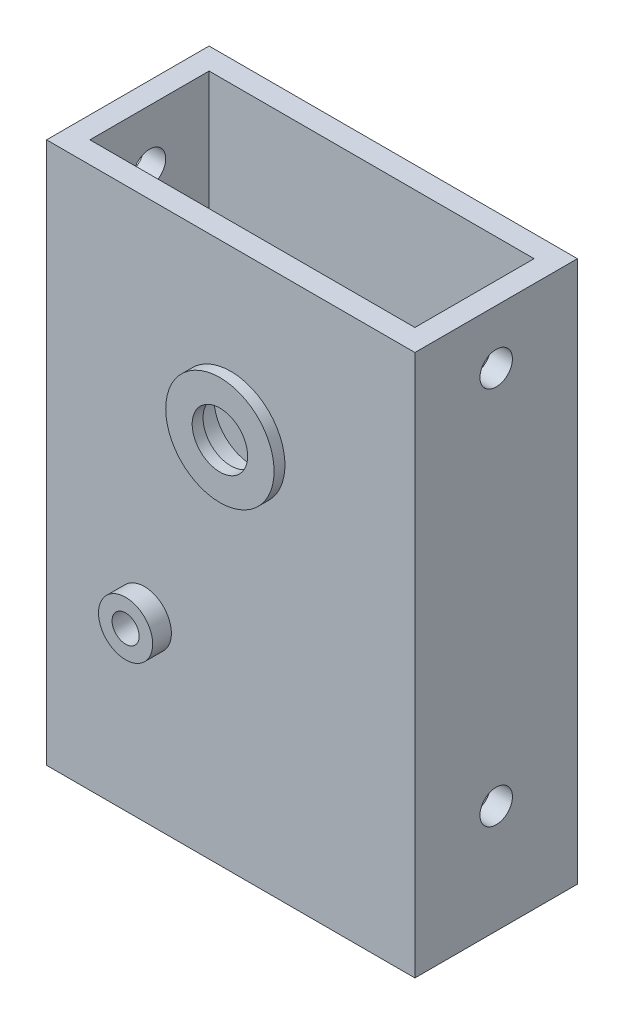
from build123d import *

# Parameters (mm, degrees)
SKETCH1_W               = 86.36
SKETCH1_H               = 38.1
SKETCH1_W_2             = 76.2
SKETCH1_H_2             = 27.94
BOSS_EXTRUDE1_DEPTH     = 127
SKETCH2_R               = 9.000000018
SKETCH2_R_2             = 3.175
CUT_EXTRUDE1_DEPTH      = 156.521858271
SKETCH3_R               = 3.81
CUT_EXTRUDE2_DEPTH      = 158.090324336
CUT_EXTRUDE2_DEPTH_BACK = 158.090324336
SKETCH4_R               = 6.35
SKETCH4_R_2             = 3.175
BOSS_EXTRUDE2_DEPTH     = 4.385
SKETCH5_R               = 6.35
SKETCH5_R_2             = 3.175
BOSS_EXTRUDE3_DEPTH     = 4.38500012
SKETCH6_R               = 12.7
SKETCH6_R_2             = 6.5
BOSS_EXTRUDE4_DEPTH     = 2.54
SKETCH7_R               = 12.7
SKETCH7_R_2             = 6.5
BOSS_EXTRUDE5_DEPTH     = 2.54


with BuildPart() as part:
    # Sketch1 → Boss-Extrude1 (new body)
    with BuildSketch(Plane(origin=(0, 0, 0), x_dir=(1, 0, 0), z_dir=(0, 1, 0))):
        with Locations((38.1, 13.97)):
            Rectangle(SKETCH1_W, SKETCH1_H)
        with Locations((38.1, 13.97)):
            Rectangle(SKETCH1_W_2, SKETCH1_H_2, mode=Mode.SUBTRACT)
    extrude(amount=BOSS_EXTRUDE1_DEPTH)

    # Sketch2 → Cut-Extrude1 (cut, through all)
    with BuildSketch(Plane.XY.offset(5.08)):
        with Locations((38.1, 88.9)):
            Circle(SKETCH2_R)
        with Locations((17.833355107, 41.428109825)):
            Circle(SKETCH2_R_2)
    extrude(amount=-CUT_EXTRUDE1_DEPTH, mode=Mode.SUBTRACT)

    # Sketch3 → Cut-Extrude2 (cut, two sides)
    with BuildSketch(Plane(origin=(81.28, 0, 0), x_dir=(0, 0, -1), z_dir=(1, 0, 0))) as cut_extrude2_sk:
        with Locations(Location((13.97, 114.3, 0), (0, 0, 180))):
            Circle(SKETCH3_R)
        with Locations(Location((13.97, 25.4, 0), (0, 0, 180))):
            Circle(SKETCH3_R)
    extrude(amount=CUT_EXTRUDE2_DEPTH, mode=Mode.SUBTRACT)
    extrude(cut_extrude2_sk.sketch, amount=-CUT_EXTRUDE2_DEPTH_BACK, mode=Mode.SUBTRACT)

    # Sketch4 → Boss-Extrude2 (add)
    with BuildSketch(Plane(origin=(0, 0, -33.02), x_dir=(-1, 0, 0), z_dir=(0, 0, -1))):
        with Locations(Location((-17.833355107, 41.428109825, 0), (0, 0, 180))):
            Circle(SKETCH4_R)
        with Locations(Location((-17.833355107, 41.428109825, 0), (0, 0, 180))):
            Circle(SKETCH4_R_2, mode=Mode.SUBTRACT)
    extrude(amount=BOSS_EXTRUDE2_DEPTH)

    # Sketch5 → Boss-Extrude3 (add)
    with BuildSketch(Plane.XY.offset(5.08)):
        with Locations((17.833355107, 41.428109825)):
            Circle(SKETCH5_R)
        with Locations((17.833355107, 41.428109825)):
            Circle(SKETCH5_R_2, mode=Mode.SUBTRACT)
    extrude(amount=BOSS_EXTRUDE3_DEPTH)

    # Sketch6 → Boss-Extrude4 (add)
    with BuildSketch(Plane.XY.offset(5.08)):
        with Locations(Location((38.1, 88.9, 0), (0, 0, 180))):
            Circle(SKETCH6_R)
        with Locations((38.1, 88.9)):
            Circle(SKETCH6_R_2, mode=Mode.SUBTRACT)
    extrude(amount=BOSS_EXTRUDE4_DEPTH)

    # Sketch7 → Boss-Extrude5 (add)
    with BuildSketch(Plane(origin=(0, 0, -33.02), x_dir=(-1, 0, 0), z_dir=(0, 0, -1))):
        with Locations((-38.1, 88.9)):
            Circle(SKETCH7_R)
        with Locations(Location((-38.1, 88.9, 0), (0, 0, 180))):
            Circle(SKETCH7_R_2, mode=Mode.SUBTRACT)
    extrude(amount=BOSS_EXTRUDE5_DEPTH)


solid = part.part
